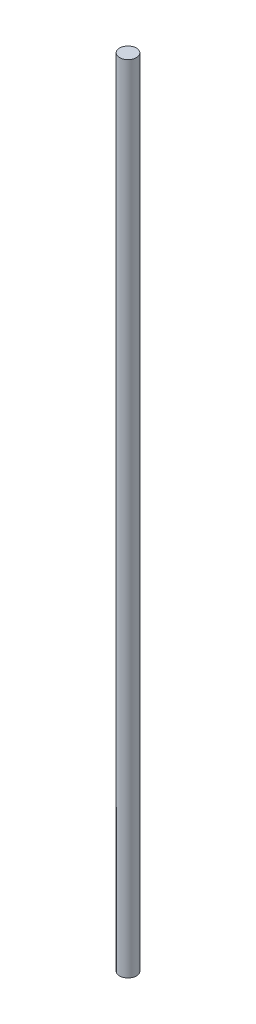
from build123d import *

# Parameters (mm, degrees)
SKETCH_1_R      = 5
EXTRUDE_1_DEPTH = 475


with BuildPart() as part:
    # 草图1 → 凸台-拉伸1 (new body)
    with BuildSketch(Plane(origin=(0, 0, 0), x_dir=(1, 0, 0), z_dir=(0, 1, 0))):
        Circle(SKETCH_1_R)
    extrude(amount=EXTRUDE_1_DEPTH)


solid = part.part
